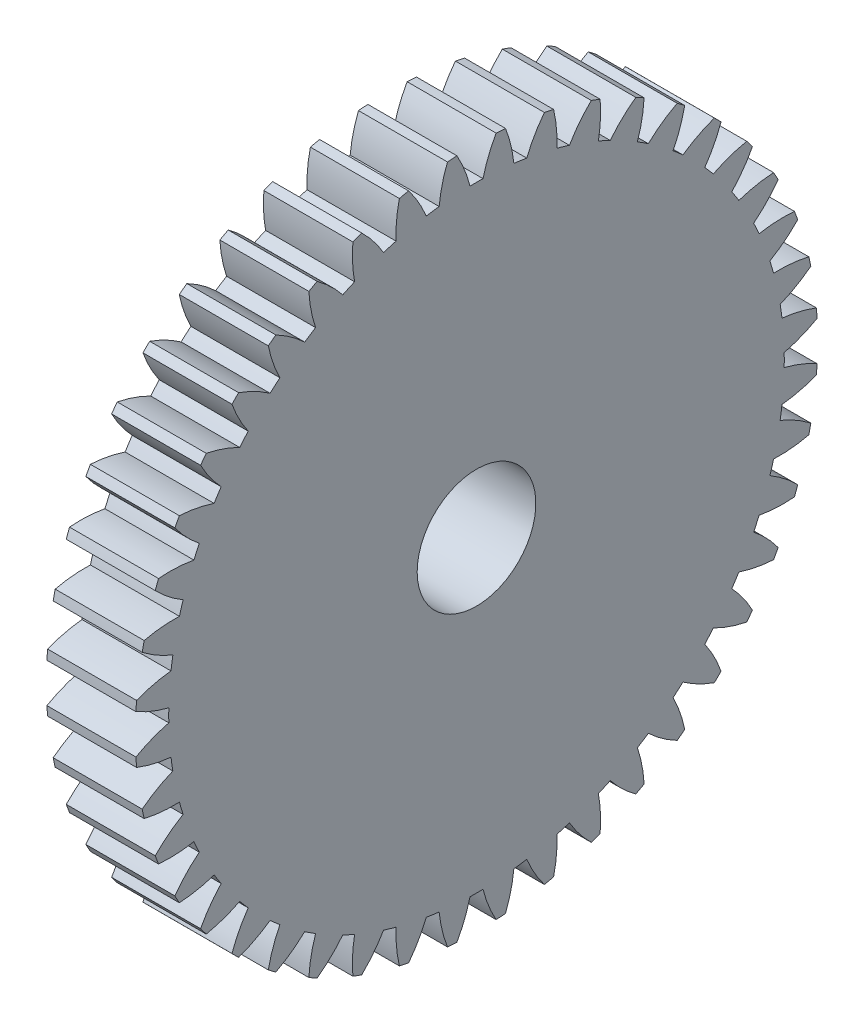
from build123d import *

# Parameters (mm, degrees)
BASPROSKE_W     = 15
BASPROSKE_H     = 57.5
TOOTHCUT_DEPTH  = 83.689177043
TEETHCUTS_COUNT = 44
TEETHCUTS_ANGLE = 351.818181818
BORSKE_R        = 10
BORE_DEPTH      = 50.0000508


with BuildPart() as part:
    # BasProSke → Base-Revolve (revolve)
    with BuildSketch(Plane(origin=(0, 0, 0), x_dir=(1, 0, 0), z_dir=(0, 1, 0)), mode=Mode.PRIVATE) as base_revolve_sk:
        with Locations((7.5, 28.75)):
            Rectangle(BASPROSKE_W, BASPROSKE_H)
    revolve(base_revolve_sk.sketch.rotate(Axis((-10, 0, 0), (1, 0, 0)), 180), axis=Axis((-10, 0, 0), (1, 0, 0)))

    # TooCutSke → ToothCut (cut, through all)
    with BuildSketch(Plane(origin=(0, 0, 0), x_dir=(0, 0, -1), z_dir=(1, 0, 0))):
        with BuildLine():
            ThreePointArc((1.096427316, 51.862411467), (0, 51.874), (-1.096427316, 51.862411467))
            ThreePointArc((-1.096427316, 51.862411467), (-2.018853505, 54.722077315), (-3.322337066, 57.429380299))
            ThreePointArc((-3.322337066, 57.429380299), (0, 57.5254), (3.322337066, 57.429380299))
            ThreePointArc((3.322337066, 57.429380299), (2.018853505, 54.722077315), (1.096427316, 51.862411467))
        make_face()
    toothcut = extrude(amount=TOOTHCUT_DEPTH, mode=Mode.SUBTRACT)

    # TeethCuts: ToothCut ×44 about axis
    teethcuts_axis = Axis((-10, 0, 0), (1, 0, 0))
    for i in range(1, TEETHCUTS_COUNT):
        add(toothcut.rotate(teethcuts_axis, i * TEETHCUTS_ANGLE / (TEETHCUTS_COUNT - 1)), mode=Mode.SUBTRACT)

    # BorSke → Bore (cut, symmetric)
    with BuildSketch(Plane(origin=(0, 0, 0), x_dir=(0, 0, -1), z_dir=(1, 0, 0))):
        with Locations(Location((0, 0, 0), (0, 0, 180))):
            Circle(BORSKE_R)
    extrude(amount=BORE_DEPTH, both=True, mode=Mode.SUBTRACT)


solid = part.part
